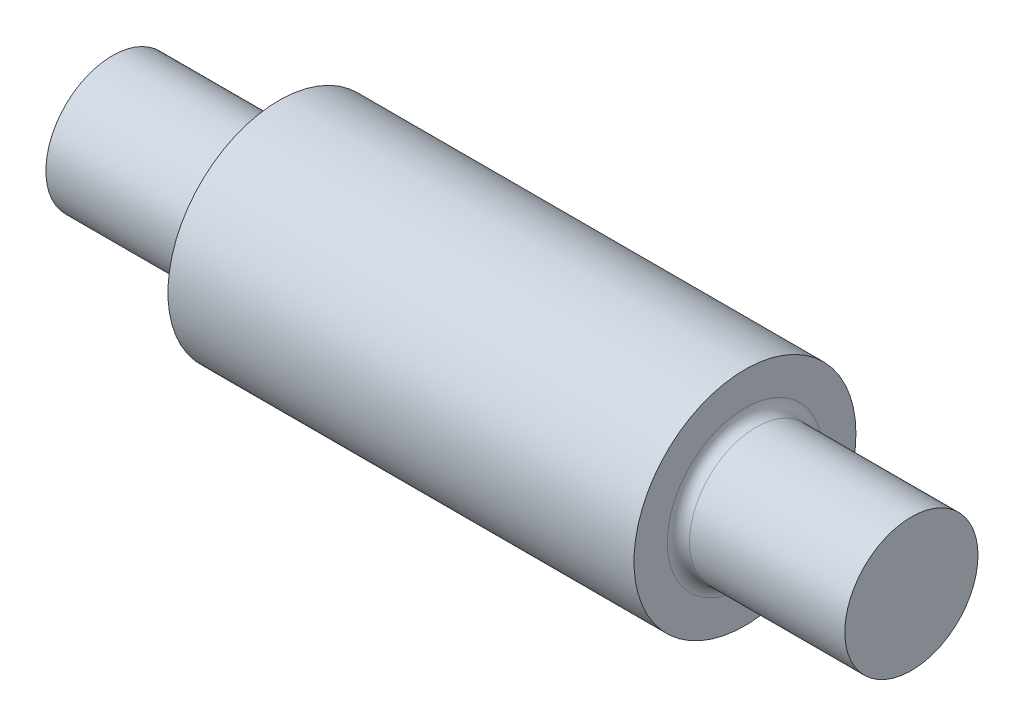
from build123d import *

# Parameters (mm, degrees)
SKETCH1_R           = 10
BOSS_EXTRUDE1_DEPTH = 21
SKETCH_1_R          = 6
EXTRUDE_1_DEPTH     = 15
FILLET_1_R          = 1


with BuildPart() as part:
    # Sketch1 → Boss-Extrude1 (new body, symmetric)
    with BuildSketch(Plane(origin=(0, 0, 0), x_dir=(0, 0, -1), z_dir=(1, 0, 0))):
        Circle(SKETCH1_R)
    extrude(amount=BOSS_EXTRUDE1_DEPTH, both=True)

    # 草图1 → 凸台-拉伸1 (add)
    with BuildSketch(Plane(origin=(21, 0, 0), x_dir=(0, 0, -1), z_dir=(1, 0, 0))):
        Circle(SKETCH_1_R)
    extrude_1 = extrude(amount=EXTRUDE_1_DEPTH)

    # 镜向1: 凸台-拉伸1 across plane
    add(extrude_1.mirror(Plane(origin=(0, 0, 0), x_dir=(0, 0, 1), z_dir=(1, 0, 0))))

    # 圆角1
    fillet_1_edges = [part.edges().sort_by_distance(p)[0] for p in [
        (-21, 0, 6),
        (21, 0, 6),
    ]]
    fillet(fillet_1_edges, radius=FILLET_1_R)


solid = part.part
